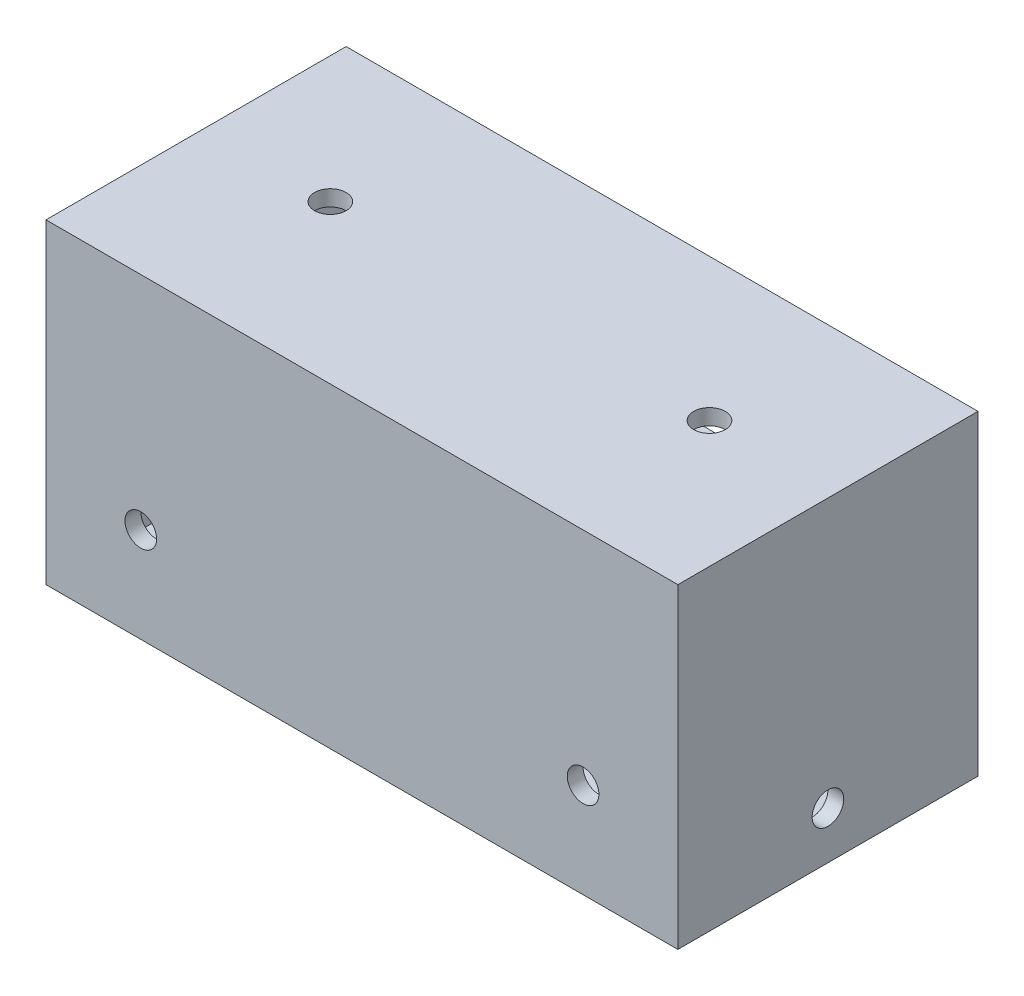
from build123d import *

# Parameters (mm, degrees)
SKETCH2_W           = 200
SKETCH2_H           = 100
SKETCH2_W_2         = 190
SKETCH2_H_2         = 90
SKETCH2_W_3         = 65.966934908
SKETCH2_H_3         = 42.5
BOSS_EXTRUDE1_DEPTH = 5
SKETCH4_W           = 200
SKETCH4_H           = 100
SKETCH4_W_2         = 190
SKETCH4_H_2         = 90
BOSS_EXTRUDE2_DEPTH = 90
SKETCH5_W           = 70
SKETCH5_H           = 22.5
CUT_EXTRUDE1_DEPTH  = 90
SKETCH6_W           = 70
SKETCH6_H           = 22.5
CUT_EXTRUDE2_DEPTH  = 90
SKETCH7_W           = 40
SKETCH7_H           = 70
CUT_EXTRUDE3_DEPTH  = 10
SKETCH8_W           = 40
SKETCH8_H           = 70
CUT_EXTRUDE4_DEPTH  = 10
SKETCH9_W           = 40
SKETCH9_H           = 70
CUT_EXTRUDE5_DEPTH  = 10
SKETCH10_R          = 2
CUT_EXTRUDE6_DEPTH  = 10
SKETCH11_R          = 5
CUT_EXTRUDE7_DEPTH  = 150
SKETCH12_R          = 5
CUT_EXTRUDE8_DEPTH  = 10
SKETCH13_R          = 5
CUT_EXTRUDE9_DEPTH  = 10
SKETCH14_R          = 5
CUT_EXTRUDE10_DEPTH = 10
SKETCH16_R          = 0.2
CUT_EXTRUDE11_DEPTH = 10
SKETCH17_W          = 40
SKETCH17_H          = 5
BOSS_EXTRUDE3_DEPTH = 70
SKETCH18_W          = 40
SKETCH18_H          = 5
BOSS_EXTRUDE4_DEPTH = 70


with BuildPart() as part:
    # Sketch2 → Boss-Extrude1 (new body)
    with BuildSketch(Plane.XY):
        Rectangle(SKETCH2_W, SKETCH2_H)
        Rectangle(SKETCH2_W_2, SKETCH2_H_2, mode=Mode.SUBTRACT)
        Polygon((-29.033065092, -2.5), (-29.033065092, -45), (95, -45), (95, 45), (-29.033065092, 45), (-29.033065092, 2.5), (-95, 2.5), (-95, -2.5), align=None)
        with Locations((-62.016532546, -23.75)):
            Rectangle(SKETCH2_W_3, SKETCH2_H_3)
        with Locations((-62.016532546, 23.75)):
            Rectangle(SKETCH2_W_3, SKETCH2_H_3)
    extrude(amount=BOSS_EXTRUDE1_DEPTH)

    # Sketch4 → Boss-Extrude2 (add)
    with BuildSketch(Plane(origin=(0, 0, 0), x_dir=(-1, 0, 0), z_dir=(0, 0, -1))):
        Rectangle(SKETCH4_W, SKETCH4_H)
        Rectangle(SKETCH4_W_2, SKETCH4_H_2, mode=Mode.SUBTRACT)
        Polygon((30, -45), (35, -45), (35, -2.5), (95, -2.5), (95, 2.5), (35, 2.5), (35, 45), (30, 45), (30, 2.5), (-30, 2.5), (-30, 45), (-35, 45), (-35, 2.5), (-95, 2.5), (-95, -2.5), (-35, -2.5), (-35, -45), (-30, -45), (-30, -2.5), (30, -2.5), align=None)
    extrude(amount=BOSS_EXTRUDE2_DEPTH)

    # Sketch5 → Cut-Extrude1 (cut)
    with BuildSketch(Plane.ZY.offset(35)):
        with Locations((-45, 23.75)):
            Rectangle(SKETCH5_W, SKETCH5_H)
    extrude(amount=-CUT_EXTRUDE1_DEPTH, mode=Mode.SUBTRACT)

    # Sketch6 → Cut-Extrude2 (cut)
    with BuildSketch(Plane.ZY.offset(35)):
        with Locations((-45, -23.75)):
            Rectangle(SKETCH6_W, SKETCH6_H)
    extrude(amount=-CUT_EXTRUDE2_DEPTH, mode=Mode.SUBTRACT)

    # Sketch7 → Cut-Extrude3 (cut)
    with BuildSketch(Plane(origin=(0, -2.5, 0), x_dir=(-1, 0, 0), z_dir=(0, -1, 0))):
        with Locations((65, 45)):
            Rectangle(SKETCH7_W, SKETCH7_H)
    extrude(amount=-CUT_EXTRUDE3_DEPTH, mode=Mode.SUBTRACT)

    # Sketch8 → Cut-Extrude4 (cut)
    with BuildSketch(Plane(origin=(0, -2.5, 0), x_dir=(-1, 0, 0), z_dir=(0, -1, 0))):
        with Locations((0, 45)):
            Rectangle(SKETCH8_W, SKETCH8_H)
    extrude(amount=-CUT_EXTRUDE4_DEPTH, mode=Mode.SUBTRACT)

    # Sketch9 → Cut-Extrude5 (cut)
    with BuildSketch(Plane(origin=(0, -2.5, 0), x_dir=(-1, 0, 0), z_dir=(0, -1, 0))):
        with Locations((-65, 45)):
            Rectangle(SKETCH9_W, SKETCH9_H)
    extrude(amount=-CUT_EXTRUDE5_DEPTH, mode=Mode.SUBTRACT)

    # Sketch10 → Cut-Extrude6 (cut)
    with BuildSketch(Plane(origin=(0, 0, -90), x_dir=(-1, 0, 0), z_dir=(0, 0, -1))):
        with Locations((32.5, 0)):
            Circle(SKETCH10_R)
        with Locations((97.5, -47.5)):
            Circle(SKETCH10_R)
        with Locations(Location((97.5, 47.5, 0), (0, 0, 180))):
            Circle(SKETCH10_R)
        with Locations((-97.5, 47.5)):
            Circle(SKETCH10_R)
        with Locations(Location((-32.5, 0, 0), (0, 0, 180))):
            Circle(SKETCH10_R)
        with Locations(Location((-97.5, -47.5, 0), (0, 0, 180))):
            Circle(SKETCH10_R)
    extrude(amount=-CUT_EXTRUDE6_DEPTH, mode=Mode.SUBTRACT)

    # Sketch11 → Cut-Extrude7 (cut)
    with BuildSketch(Plane(origin=(0, -50, 0), x_dir=(-1, 0, 0), z_dir=(0, -1, 0))):
        with Locations(Location((60, 45, 0), (0, 0, 90))):
            Circle(SKETCH11_R)
        with Locations(Location((-60, 45, 0), (0, 0, 90))):
            Circle(SKETCH11_R)
    extrude(amount=-CUT_EXTRUDE7_DEPTH, mode=Mode.SUBTRACT)

    # Sketch12 → Cut-Extrude8 (cut)
    with BuildSketch(Plane.ZY.offset(100)):
        with Locations(Location((-42.5, -35, 0), (0, 0, 270))):
            Circle(SKETCH12_R)
    extrude(amount=-CUT_EXTRUDE8_DEPTH, mode=Mode.SUBTRACT)

    # Sketch13 → Cut-Extrude9 (cut)
    with BuildSketch(Plane(origin=(100, 0, 0), x_dir=(0, 0, -1), z_dir=(1, 0, 0))):
        with Locations(Location((42.5, -35, 0), (0, 0, 270))):
            Circle(SKETCH13_R)
    extrude(amount=-CUT_EXTRUDE9_DEPTH, mode=Mode.SUBTRACT)

    # Sketch14 → Cut-Extrude10 (cut)
    with BuildSketch(Plane.XY.offset(5)):
        with Locations((-70, -20)):
            Circle(SKETCH14_R)
        with Locations((70, -20)):
            Circle(SKETCH14_R)
    extrude(amount=-CUT_EXTRUDE10_DEPTH, mode=Mode.SUBTRACT)

    # Sketch16 → Cut-Extrude11 (cut)
    with BuildSketch(Plane.XZ.offset(50)):
        with Locations(Location((90, -5, 0), (0, 0, 270))):
            Circle(SKETCH16_R)
        with Locations(Location((91.7083249, -6.825274236, 0), (0, 0, 270))):
            Circle(SKETCH16_R)
        with Locations(Location((88.2916751, -3.174725764, 0), (0, 0, 270))):
            Circle(SKETCH16_R)
        with Locations(Location((-91.7083249, -6.825274236, 0), (0, 0, 270))):
            Circle(SKETCH16_R)
        with Locations(Location((-90, -5, 0), (0, 0, 270))):
            Circle(SKETCH16_R)
        with Locations(Location((-88.2916751, -3.174725764, 0), (0, 0, 270))):
            Circle(SKETCH16_R)
        with Locations(Location((88.2916751, -86.825274236, 0), (0, 0, 270))):
            Circle(SKETCH16_R)
        with Locations(Location((90, -85, 0), (0, 0, 270))):
            Circle(SKETCH16_R)
        with Locations(Location((91.7083249, -83.174725764, 0), (0, 0, 270))):
            Circle(SKETCH16_R)
        with Locations(Location((-88.2916751, -86.825274236, 0), (0, 0, 270))):
            Circle(SKETCH16_R)
        with Locations(Location((-90, -85, 0), (0, 0, 270))):
            Circle(SKETCH16_R)
        with Locations(Location((-91.7083249, -83.174725764, 0), (0, 0, 270))):
            Circle(SKETCH16_R)
    extrude(amount=-CUT_EXTRUDE11_DEPTH, mode=Mode.SUBTRACT)

    # Sketch17 → Boss-Extrude3 (add)
    with BuildSketch(Plane(origin=(0, 0, -10), x_dir=(-1, 0, 0), z_dir=(0, 0, -1))):
        with Locations((65, 0)):
            Rectangle(SKETCH17_W, SKETCH17_H)
    extrude(amount=BOSS_EXTRUDE3_DEPTH)

    # Sketch18 → Boss-Extrude4 (add)
    with BuildSketch(Plane(origin=(0, 0, -10), x_dir=(-1, 0, 0), z_dir=(0, 0, -1))):
        with Locations((-65, 0)):
            Rectangle(SKETCH18_W, SKETCH18_H)
    extrude(amount=BOSS_EXTRUDE4_DEPTH)


solid = part.part
